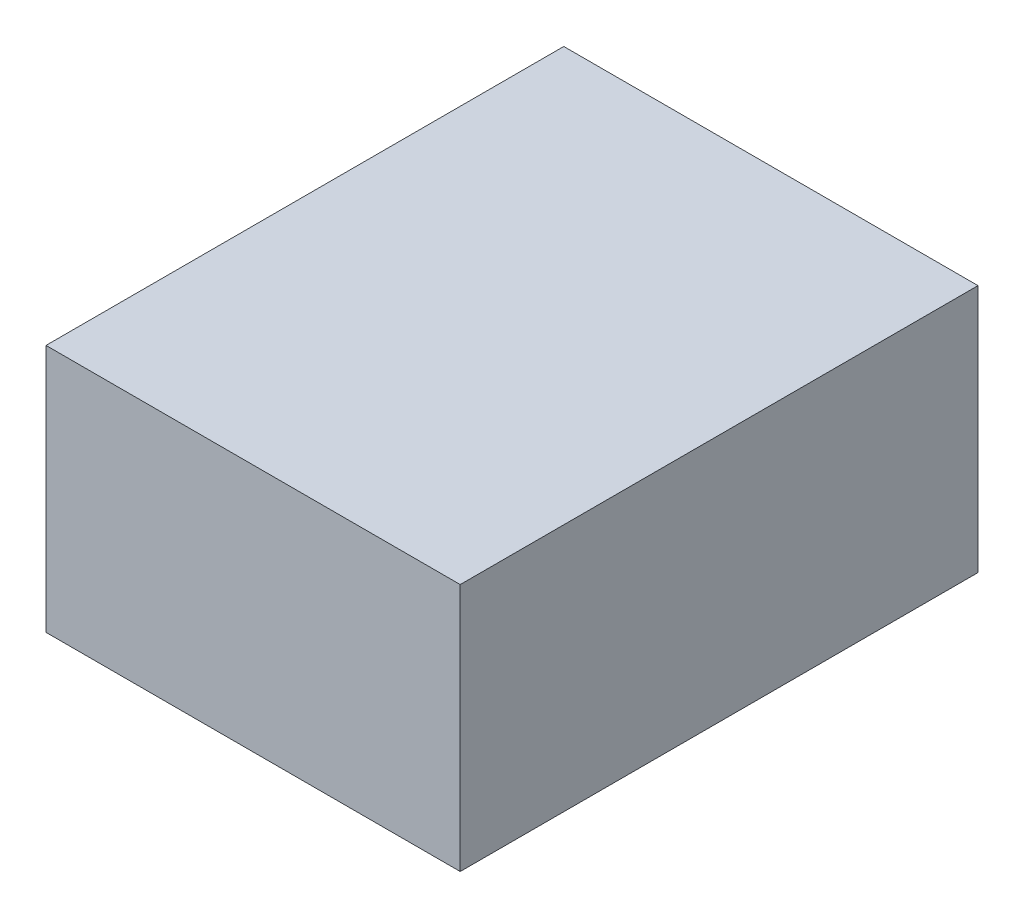
from build123d import *

# Parameters (mm, degrees)
BASES_W    = 2
BASES_H    = 2.5
BASE_DEPTH = 1.2


with BuildPart() as part:
    # BaseS → Base (new body)
    with BuildSketch(Plane(origin=(0, 0, 0), x_dir=(1, 0, 0), z_dir=(0, 1, 0))):
        Rectangle(BASES_W, BASES_H)
    extrude(amount=BASE_DEPTH)


solid = part.part
